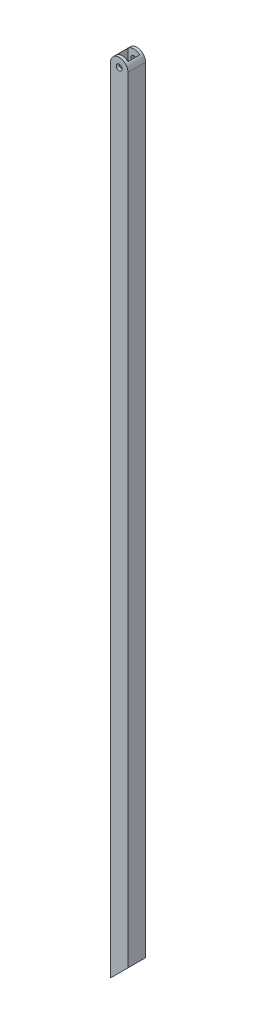
from build123d import *

# Parameters (mm, degrees)
ESQUISSE1_R             = 3.175
BOSS_EXTRU_1_DEPTH      = 19.05
ESQUISSE2_W             = 12.7
ESQUISSE2_H             = 12.7
ENL_V_MAT_EXTRU_3_DEPTH = 871


with BuildPart() as part:
    # Esquisse1 → Boss.-Extru.1 (new body)
    with BuildSketch(Plane.XY):
        with BuildLine():
            Line((0, 0), (19.05, 19.05))
            Line((19.05, 19.05), (19.05, 860.475))
            ThreePointArc((19.05, 860.475), (9.525, 870), (0, 860.475))
            Line((0, 860.475), (0, 0))
        make_face()
        with Locations((9.525, 860.475)):
            Circle(ESQUISSE1_R, mode=Mode.SUBTRACT)
    extrude(amount=BOSS_EXTRU_1_DEPTH)

    # Esquisse2 → Enlèv. mat.-Extru.3 (cut, through all)
    with BuildSketch(Plane(origin=(0, 0, 0), x_dir=(1, 0, 0), z_dir=(0, 1, 0))):
        with Locations((9.525, -9.525)):
            Rectangle(ESQUISSE2_W, ESQUISSE2_H)
    extrude(amount=ENL_V_MAT_EXTRU_3_DEPTH, mode=Mode.SUBTRACT)


solid = part.part
